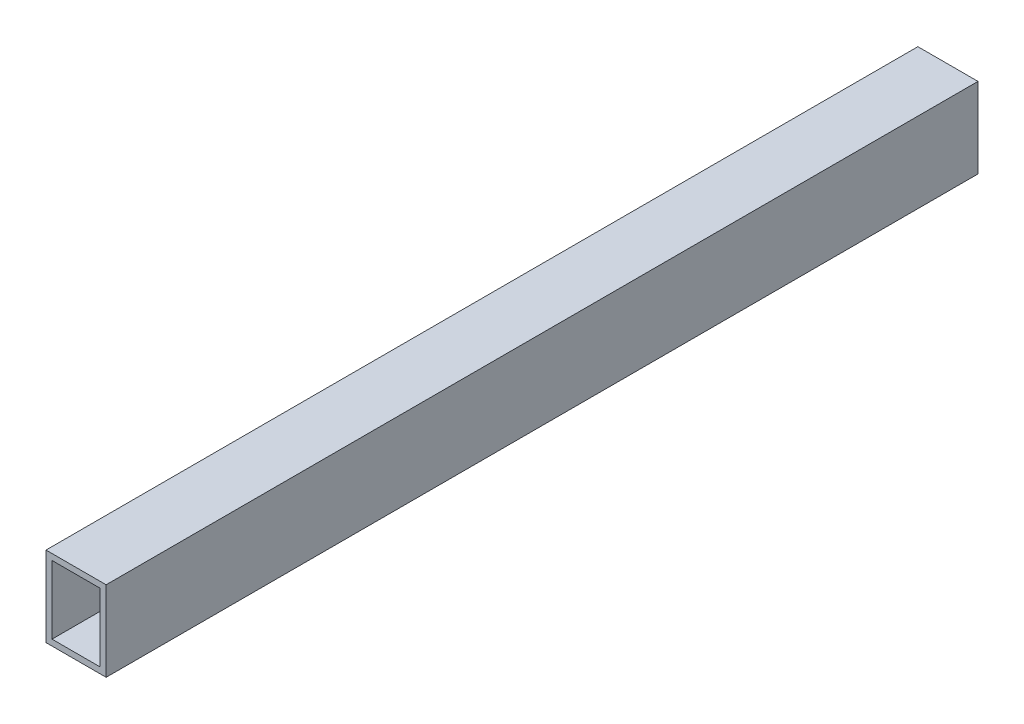
from build123d import *

# Parameters (mm, degrees)
CROQUIS1_W              = 435
CROQUIS1_H              = 40
SALIENTE_EXTRUIR1_DEPTH = 30
CROQUIS2_W              = 24
CROQUIS2_H              = 34
CORTAR_EXTRUIR1_DEPTH   = 890


with BuildPart() as part:
    # Croquis1 → Saliente-Extruir1 (new body)
    with BuildSketch(Plane(origin=(0, 0, 0), x_dir=(0, 0, -1), z_dir=(1, 0, 0))):
        Rectangle(CROQUIS1_W, CROQUIS1_H)
    extrude(amount=SALIENTE_EXTRUIR1_DEPTH)

    # Croquis2 → Cortar-Extruir1 (cut)
    with BuildSketch(Plane.XY.offset(217.5)):
        with Locations((15, 0)):
            Rectangle(CROQUIS2_W, CROQUIS2_H)
    extrude(amount=-CORTAR_EXTRUIR1_DEPTH, mode=Mode.SUBTRACT)


solid = part.part
